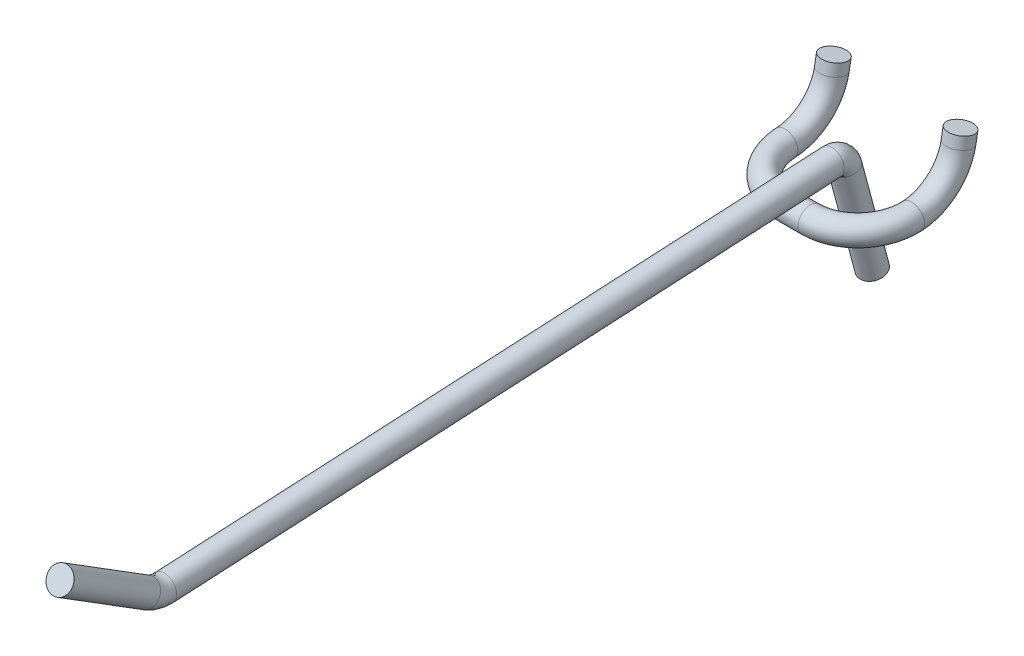
from build123d import *

# Parameters (mm, degrees)
SKETCH2_R = 2.54
SKETCH3_R = 2.54
SKETCH7_R = 2.54


with BuildPart() as part:
    # Sweep1: sweep along a path in Sketch1
    with BuildLine(Plane(origin=(0, 0, 0), x_dir=(0, 0, -1), z_dir=(1, 0, 0))) as sweep1_path:
        Line((0, 0), (-129.667234525, -6.795571807))
        ThreePointArc((-129.667234525, -6.795571807), (-131.589480873, -6.602011778), (-133.364555175, -5.839379672))
        Line((-133.364555175, -5.839379672), (-151.13, 5.261702322))
    # Sketch2 → Sweep1 (sweep)
    with BuildSketch(Plane.XY):
        Circle(SKETCH2_R)
    sweep(path=sweep1_path.line)

    # Sweep2: sweep along a path in Sketch4
    with BuildLine(Plane(origin=(0, 0, 0), x_dir=(0, 0, -1), z_dir=(1, 0, 0))) as sweep2_path:
        Line((15.24, -22.86), (9.520812242, -1.515700708))
        ThreePointArc((9.520812242, -1.515700708), (8.560335184, -0.118197916), (6.934427314, 0.363417936))
        Line((6.934427314, 0.363417936), (0, 0))
    # Sketch3 → Sweep2 (sweep)
    with BuildSketch(Plane.XY):
        Circle(SKETCH3_R)
    sweep(path=sweep2_path.line)

    # SurfaceCut1
    split(bisect_by=Plane(origin=(0, 5.19125839, 151.017266144), x_dir=(-1, 0, 0), z_dir=(0, -0.5299192642332059, -0.8480480961564255)), keep=Keep.TOP)

    # SurfaceCut2
    split(bisect_by=Plane(origin=(0, -22.731596264, -15.205594323), x_dir=(1, 0, 0), z_dir=(0, -0.965925826289068, -0.25881904510252185)), keep=Keep.BOTTOM)


with BuildPart() as body_2:
    # Sweep3: sweep along a curve in space
    with BuildLine() as sweep3_path:
        Line((0, -5.066085614, -0.265502297), (2.54, -5.066085614, -0.265502297))
        ThreePointArc((2.54, -5.066085614, -0.265502297), (9.724204897, -4.910344532, -3.237219176), (12.7, -4.534352299, -10.41157837))
        Line((12.7, -4.534352299, -10.41157837), (12.7, -4.532992073, -10.437533031))
        ThreePointArc((12.7, -4.532992073, -10.437533031), (12.7, -1.996306123, -16.638019406), (12.7, 3.848818515, -19.911446487))
        Line((12.7, 3.848818515, -19.911446487), (12.7, 6.165840628, -20.32))
    # Sketch7 → Sweep3 (sweep)
    with BuildSketch(Plane(origin=(0, 0, 0), x_dir=(0, 0, -1), z_dir=(1, 0, 0))):
        with Locations((0, -5.08)):
            Circle(SKETCH7_R)
    sweep(path=sweep3_path.line)

    # Mirror2: body 2 across plane


with BuildPart() as body_2_1:
    add(body_2.part)
    add(body_2.part.mirror(Plane(origin=(0, 0, 0), x_dir=(0, 0, 1), z_dir=(1, 0, 0))))


solid = Compound([part.part, body_2_1.part])
